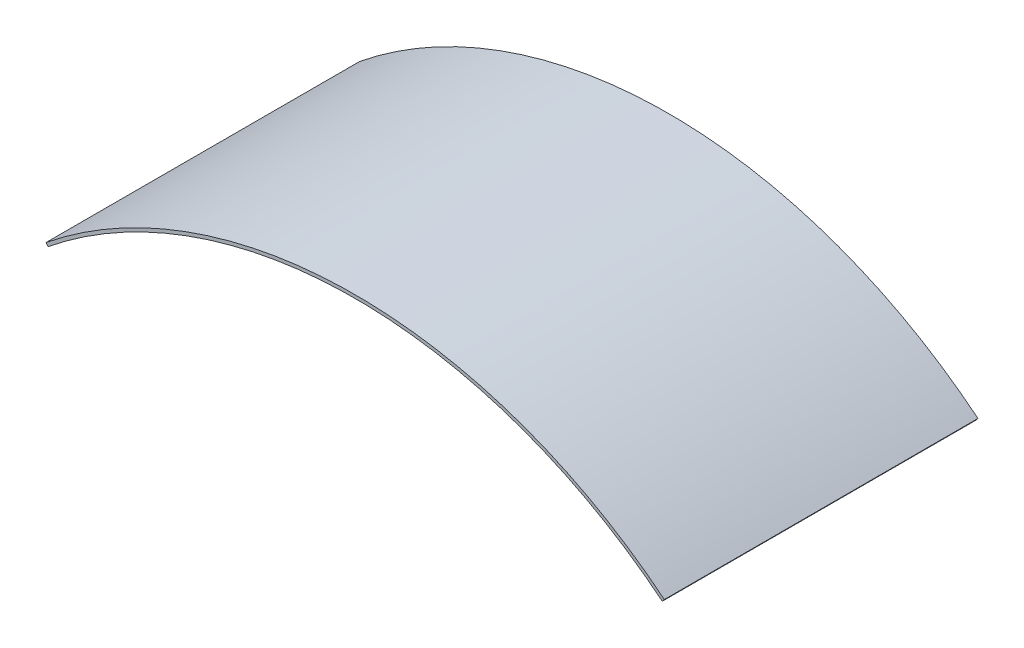
from build123d import *

# Parameters (mm, degrees)
BOSS_EXTRUDE1_DEPTH = 152.4


with BuildPart() as part:
    # Sketch1 → Boss-Extrude1 (new body, symmetric)
    with BuildSketch(Plane.XY):
        with BuildLine():
            Line((-298.45, 0), (-300.44691872, 2.468388265))
            ThreePointArc((-300.44691872, 2.468388265), (0, 108.781838287), (300.44691872, 2.468388265))
            Line((300.44691872, 2.468388265), (298.45, 0))
            ThreePointArc((298.45, 0), (0, 105.606838287), (-298.45, 0))
        make_face()
    extrude(amount=BOSS_EXTRUDE1_DEPTH, both=True)


solid = part.part
